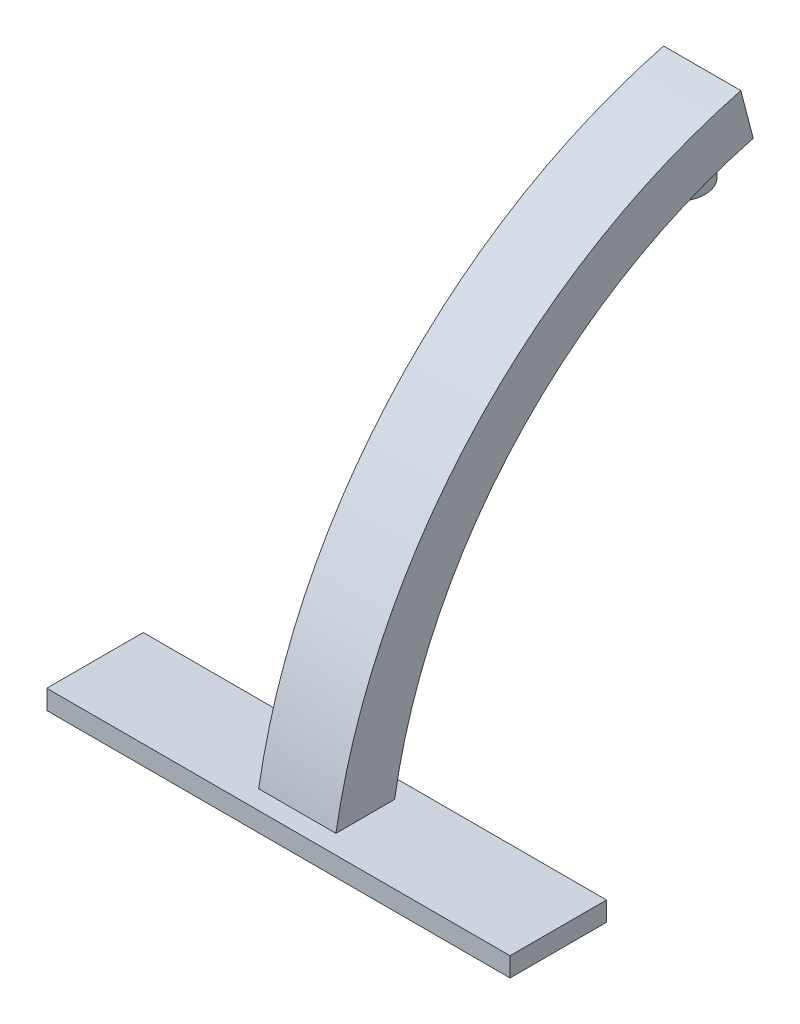
from build123d import *

# Parameters (mm, degrees)
SKETCH1_W                = 152.4
SKETCH1_H                = 31.75
BOSS_EXTRUDE1_DEPTH      = 6.35
BOSS_EXTRUDE2_DEPTH      = 12.7
BOSS_EXTRUDE2_DEPTH_BACK = 12.7
SKETCH7_R                = 9.525
BOSS_EXTRUDE4_DEPTH      = 12.7
BOSS_EXTRUDE5_REACH      = 250.235
BOSS_EXTRUDE5_END_RADIUS = 159.352919158
SKETCH8_W                = 17.78
SKETCH8_H                = 25.4


with BuildPart() as part:
    # Sketch1 → Boss-Extrude1 (new body)
    with BuildSketch(Plane(origin=(0, 0, 0), x_dir=(1, 0, 0), z_dir=(0, 1, 0))):
        with Locations((76.2, 15.875)):
            Rectangle(SKETCH1_W, SKETCH1_H)
    extrude(amount=BOSS_EXTRUDE1_DEPTH)

    # Sketch5 → Boss-Extrude2 (add, two sides)
    with BuildSketch(Plane(origin=(76.2, 0, 0), x_dir=(0, 0, -1), z_dir=(1, 0, 0))) as boss_extrude2_sk:
        with BuildLine():
            Line((6.218121971, 6.35), (25.531878029, 6.35))
            ThreePointArc((25.531878029, 6.35), (65.347005213, 88.504842335), (143.500563524, 135.69259281))
            Line((143.500563524, 135.69259281), (139.418467432, 151.35))
            ThreePointArc((139.418467432, 151.35), (51.469243862, 98.46173067), (6.218121971, 6.35))
        make_face()
    extrude(amount=BOSS_EXTRUDE2_DEPTH)
    extrude(boss_extrude2_sk.sketch, amount=-BOSS_EXTRUDE2_DEPTH_BACK)

    # Sketch7 → Boss-Extrude4 (add)
    with BuildSketch(Plane(origin=(0, 137.16, 0), x_dir=(1, 0, 0), z_dir=(0, 1, 0))):
        with Locations(Location((76.2, 130.81, 0), (0, 0, 270))):
            Circle(SKETCH7_R)
    extrude(amount=-BOSS_EXTRUDE4_DEPTH)

    # Boss-Extrude5: up to this cylinder (the profile starts outside it)
    boss_extrude5_end = Plane(origin=(76.2, -19.734844364, -184.022581395), z_dir=(1, 0, 0)) * Cylinder(BOSS_EXTRUDE5_END_RADIUS, 820.175838317, mode=Mode.PRIVATE)
    # Sketch8 → Boss-Extrude5 (add, up to the surface)
    with BuildSketch(Plane(origin=(0, 0, -19.05), x_dir=(-1, 0, 0), z_dir=(0, 0, -1)), mode=Mode.PRIVATE) as boss_extrude5_sk1:
        with Locations((-76.2, 25.4)):
            Rectangle(SKETCH8_W, SKETCH8_H)
    boss_extrude5_tool1 = extrude(boss_extrude5_sk1.sketch, amount=BOSS_EXTRUDE5_REACH, mode=Mode.PRIVATE) - boss_extrude5_end
    add(boss_extrude5_tool1.solids().sort_by_distance((76.2, 25.4, -19.05))[0])


solid = part.part
